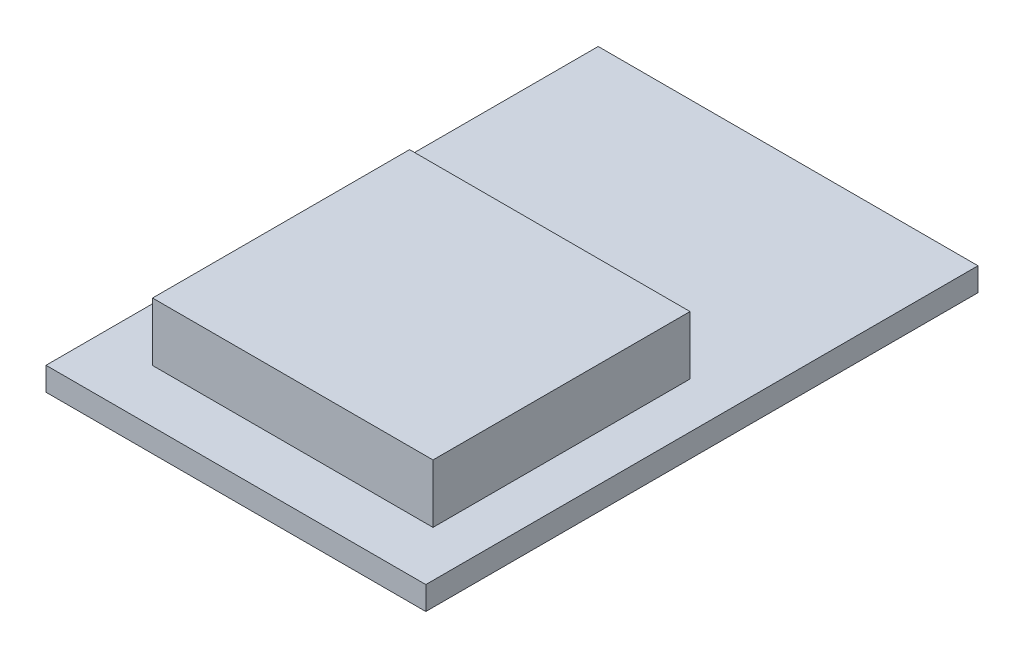
from build123d import *

# Parameters (mm, degrees)
SKETCH1_W           = 13
SKETCH1_H           = 18.9
BOSS_EXTRUDE1_DEPTH = 0.8
SKETCH2_W           = 9.599427918
SKETCH2_H           = 8.797319385
BOSS_EXTRUDE2_DEPTH = 2


with BuildPart() as part:
    # Sketch1 → Boss-Extrude1 (new body)
    with BuildSketch(Plane(origin=(0, 0, 0), x_dir=(1, 0, 0), z_dir=(0, 1, 0))):
        with Locations((6.5, 9.45)):
            Rectangle(SKETCH1_W, SKETCH1_H)
    extrude(amount=BOSS_EXTRUDE1_DEPTH)

    # Sketch2 → Boss-Extrude2 (add)
    with BuildSketch(Plane(origin=(0, 0.8, 0), x_dir=(1, 0, 0), z_dir=(0, 1, 0))):
        with Locations((6.629372344, 6.215691403)):
            Rectangle(SKETCH2_W, SKETCH2_H)
    extrude(amount=BOSS_EXTRUDE2_DEPTH)


solid = part.part
